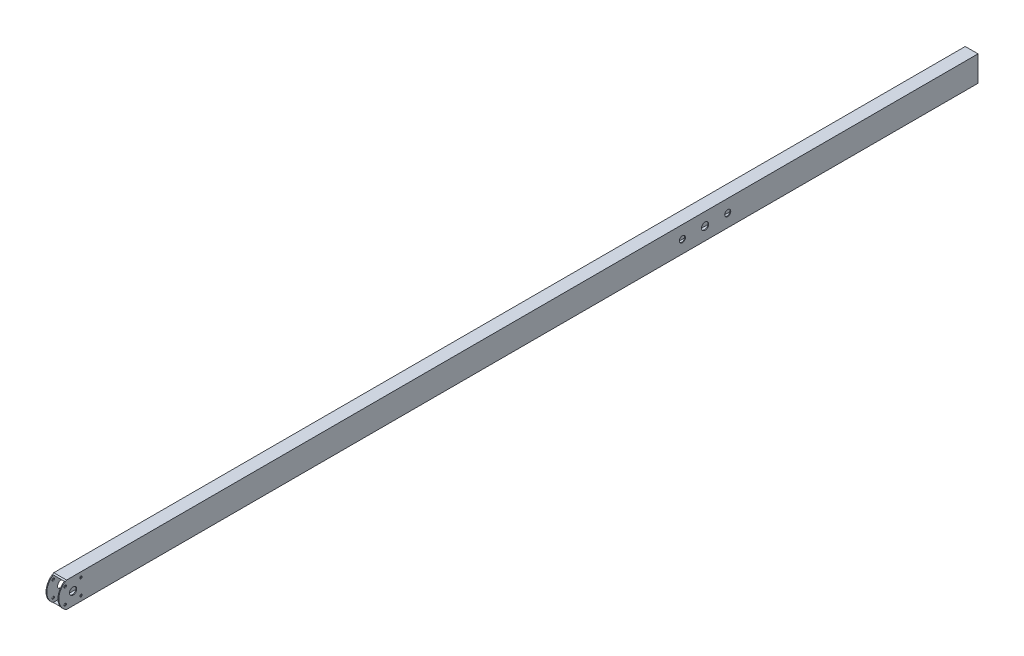
from build123d import *

# Parameters (mm, degrees)
SKETCH2_W                      = 25.4
SKETCH2_H                      = 50.8
SKETCH2_W_2                    = 22.225
SKETCH2_H_2                    = 47.625
EXTRUDE_THIN2_DEPTH            = 1828.8
CUT_EXTRUDE1_DEPTH             = 26.4
F_9_16_0_5625_DIAMETER_HOLE1_D = 14.2875
F_9_16_0_5625_DIAMETER_HOLE2_D = 14.2875
F_12_0MM_DOWEL_HOLE1_D         = 12
F_3_16_0_1875_DIAMETER_HOLE1_D = 4.7625


with BuildPart() as part:
    # Sketch2 → Extrude-Thin2 (new body)
    with BuildSketch(Plane.XY):
        Rectangle(SKETCH2_W, SKETCH2_H)
        Rectangle(SKETCH2_W_2, SKETCH2_H_2, mode=Mode.SUBTRACT)
    extrude(amount=EXTRUDE_THIN2_DEPTH)

    # Sketch8 → Cut-Extrude1 (cut, through all)
    with BuildSketch(Plane(origin=(12.7, 0, 0), x_dir=(0, 0, -1), z_dir=(1, 0, 0))):
        with BuildLine():
            Line((-1828.8, 25.4), (-1828.8, -3.09e-07))
            ThreePointArc((-1828.8, -3.09e-07), (-1824.623790622, 14.87379041), (-1813.315860361, 25.4))
            Line((-1813.315860361, 25.4), (-1828.8, 25.4))
        make_face()
        with BuildLine():
            Line((-1828.8, -25.4), (-1813.315860361, -25.4))
            ThreePointArc((-1813.315860361, -25.4), (-1824.623790462, -14.873790674), (-1828.8, -3.09e-07))
            Line((-1828.8, -3.09e-07), (-1828.8, -25.4))
        make_face()
    extrude(amount=-CUT_EXTRUDE1_DEPTH, mode=Mode.SUBTRACT)

    # 9/16 (0.5625) Diameter Hole1 (through all)
    with Locations(Plane(origin=(12.7, 0, 0), x_dir=(0, 0, -1), z_dir=(1, 0, 0))):
        with Locations((-1800.225, 0)):
            Hole(F_9_16_0_5625_DIAMETER_HOLE1_D / 2)

    # 9/16 (0.5625) Diameter Hole2 (through all)
    with Locations(Plane(origin=(12.7, 0, 0), x_dir=(0, 0, -1), z_dir=(1, 0, 0))):
        with Locations((-542.925, 0)):
            Hole(F_9_16_0_5625_DIAMETER_HOLE2_D / 2)

    # Ø12.0mm Dowel Hole1 (through all)
    with Locations(Plane(origin=(12.7, 0, 0), x_dir=(0, 0, -1), z_dir=(1, 0, 0))):
        with Locations((-587.9703125, 0), (-497.8796875, 0)):
            Hole(F_12_0MM_DOWEL_HOLE1_D / 2)

    # 3/16 (0.1875) Diameter Hole1 (through all)
    with Locations(Plane(origin=(12.7, 0, 0), x_dir=(0, 0, -1), z_dir=(1, 0, 0))):
        with Locations((-1784.509551788, 15.715448212), (-1784.509551788, -15.715448212), (-1815.940448212, -15.715448212), (-1815.940448212, 15.715448212)):
            Hole(F_3_16_0_1875_DIAMETER_HOLE1_D / 2)


solid = part.part
